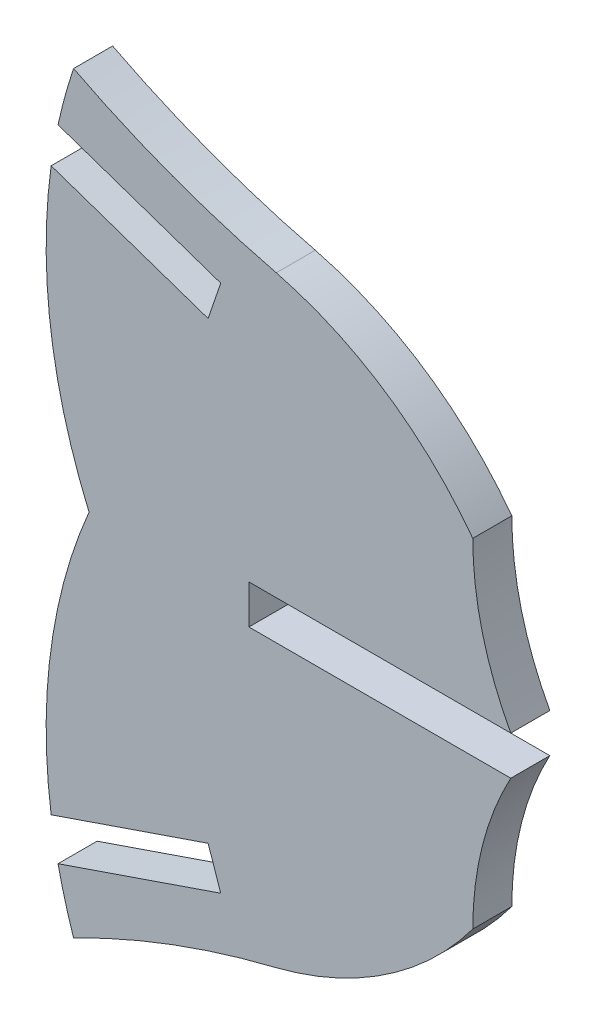
from build123d import *

# Parameters (mm, degrees)
BOSS_EXTRUDE1_DEPTH = 1.524


with BuildPart() as part:
    # Sketch1 → Boss-Extrude1 (new body)
    with BuildSketch(Plane.XY):
        with BuildLine():
            Line((0.285426682, 0), (0.285426682, -1.524))
            Line((0.285426682, -1.524), (10.508401923, -1.524))
            ThreePointArc((10.508401923, -1.524), (9.401321759, -4.352342754), (9.024565628, -7.366178191))
            ThreePointArc((9.024565628, -7.366178191), (5.632541896, -10.599139275), (1.353650751, -12.509362545))
            ThreePointArc((1.353650751, -12.509362545), (-2.688908753, -13.751919893), (-6.559224402, -15.456881148))
            ThreePointArc((-6.559224402, -15.456881148), (-6.892797133, -14.362674131), (-7.1651622, -13.251648913))
            Line((-7.1651622, -13.251648913), (-0.813548275, -11.074651995))
            Line((-0.813548275, -11.074651995), (-1.307676516, -9.632981686))
            Line((-1.307676516, -9.632981686), (-7.434081645, -11.732788954))
            ThreePointArc((-7.434081645, -11.732788954), (-7.444704809, -6.146254485), (-5.954978709, -0.762))
            ThreePointArc((-5.954978709, -0.762), (-7.444704809, 4.622254485), (-7.434081645, 10.208788954))
            Line((-7.434081645, 10.208788954), (-1.307676516, 8.108981686))
            Line((-1.307676516, 8.108981686), (-0.813548275, 9.550651995))
            Line((-0.813548275, 9.550651995), (-7.1651622, 11.727648913))
            ThreePointArc((-7.1651622, 11.727648913), (-6.892797133, 12.838674131), (-6.559224402, 13.932881148))
            ThreePointArc((-6.559224402, 13.932881148), (-2.688908753, 12.227919893), (1.353650751, 10.985362545))
            ThreePointArc((1.353650751, 10.985362545), (5.632541896, 9.075139275), (9.024565628, 5.842178191))
            ThreePointArc((9.024565628, 5.842178191), (9.401321759, 2.828342754), (10.508401923, 0))
            Line((10.508401923, 0), (0.285426682, 0))
        make_face()
    extrude(amount=BOSS_EXTRUDE1_DEPTH)


solid = part.part
